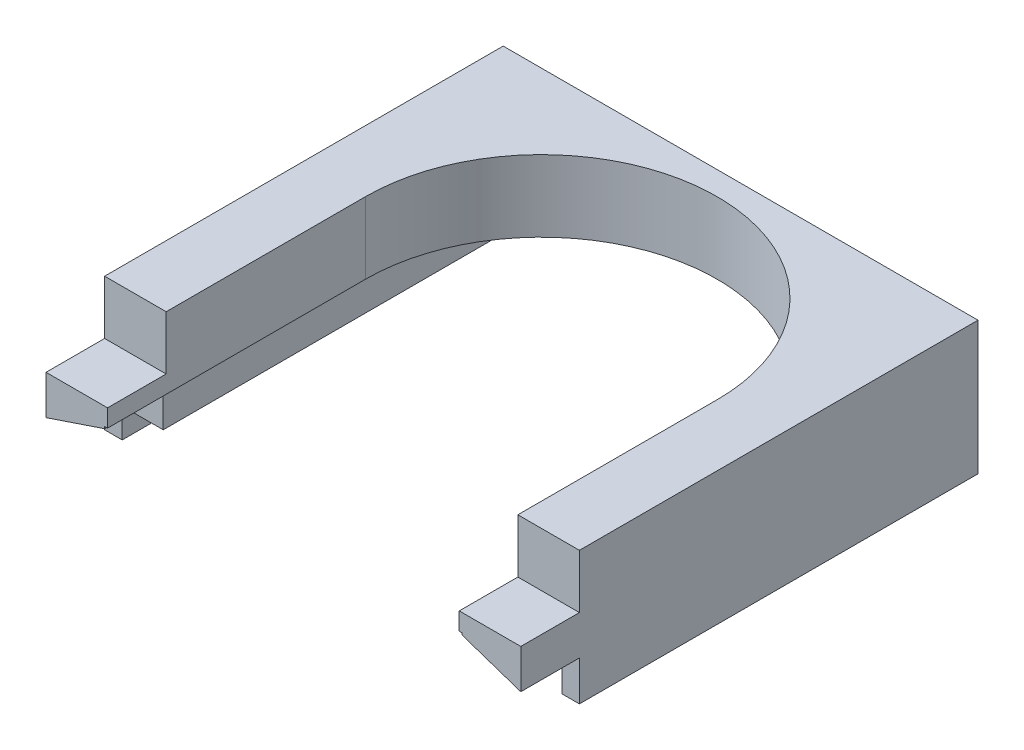
from build123d import *

# Parameters (mm, degrees)
BOSS_EXTRU_1_DEPTH      = 68
ENL_V_MAT_EXTRU_1_DEPTH = 30
BOSS_EXTRU_2_DEPTH      = 10


with BuildPart() as part:
    # Esquisse1 → Boss.-Extru.1 (new body)
    with BuildSketch(Plane.XY):
        Polygon((-32.503867199, -5.5), (-32.503867199, -10.5), (-35.503867199, -10.5), (-35.503867199, 12.2), (45.496132801, 12.2), (45.496132801, -10.5), (42.496132801, -10.5), (42.496132801, -5.5), (35.496132801, -5.5), (35.496132801, 0), (-25.503867199, 0), (-25.503867199, -5.5), align=None)
    extrude(amount=BOSS_EXTRU_1_DEPTH)

    # Esquisse2 → Enlèv. mat.-Extru.1 (cut)
    with BuildSketch(Plane(origin=(0, 12.2, 0), x_dir=(1, 0, 0), z_dir=(0, 1, 0))):
        with BuildLine():
            Line((-25.003867199, -34), (-25.003867199, -68))
            Line((-25.003867199, -68), (34.996132801, -68))
            Line((34.996132801, -68), (34.996132801, -34))
            ThreePointArc((34.996132801, -34), (4.996132801, -4), (-25.003867199, -34))
        make_face()
    extrude(amount=-ENL_V_MAT_EXTRU_1_DEPTH, mode=Mode.SUBTRACT)

    # Esquisse3 → Boss.-Extru.2 (add)
    with BuildSketch(Plane.XY.offset(68)):
        Polygon((-35.503867199, -3.7), (-35.503867199, 3), (-25.003867199, 3), (-25.003867199, 0), (-25.503867199, 0), (-25.503867199, -0.338080905), align=None)
        Polygon((35.496132801, -0.338080905), (35.496132801, 0), (34.996132801, 0), (34.996132801, 3), (45.496132801, 3), (45.496132801, -3.7), align=None)
    extrude(amount=BOSS_EXTRU_2_DEPTH)


solid = part.part
